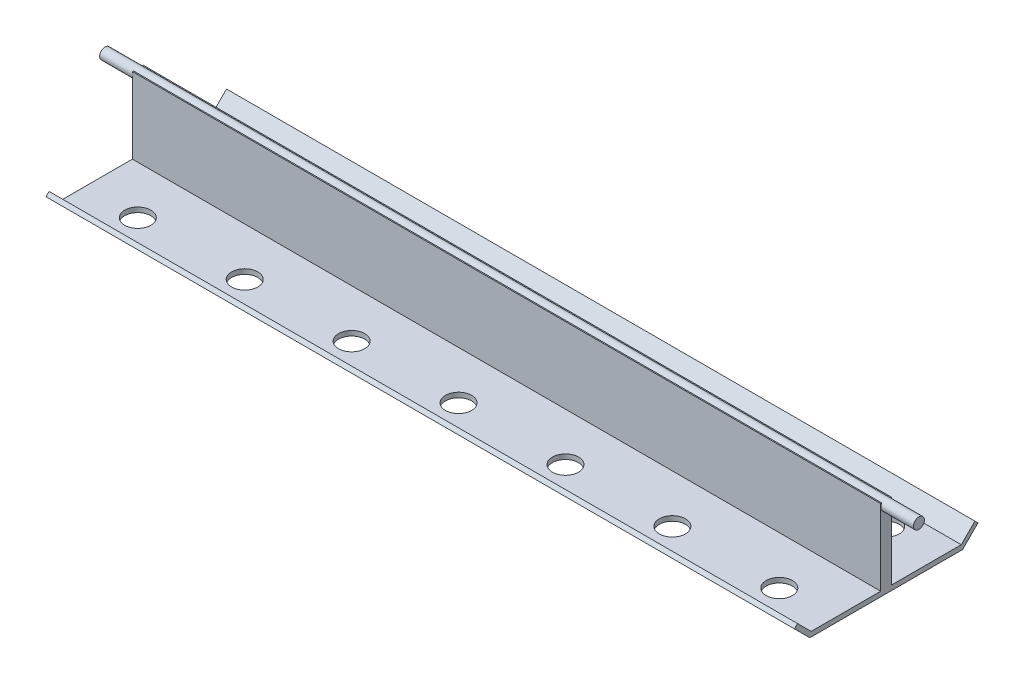
from build123d import *

# Parameters (mm, degrees)
SKETCH3_W                = 343
SKETCH3_H                = 5
BOSS_EXTRUDE1_DEPTH      = 35
SKETCH6_R                = 2.5
BOSS_EXTRUDE3_DEPTH      = 15
BOSS_EXTRUDE3_DEPTH_BACK = 358
BOSS_EXTRUDE4_DEPTH      = 343
SKETCH8_R                = 6
SKETCH8_R_2              = 5.999960458
CUT_EXTRUDE1_DEPTH       = 2.23071


with BuildPart() as part:
    # Sketch3 → Boss-Extrude1 (new body)
    with BuildSketch(Plane(origin=(0, 0, 0), x_dir=(1, 0, 0), z_dir=(0, 1, 0))):
        Rectangle(SKETCH3_W, SKETCH3_H)
    extrude(amount=BOSS_EXTRUDE1_DEPTH)

    # Sketch6 → Boss-Extrude3 (add, two sides)
    with BuildSketch(Plane.ZY.offset(171.5)) as boss_extrude3_sk:
        with Locations((0, 33.5)):
            Circle(SKETCH6_R)
    extrude(amount=BOSS_EXTRUDE3_DEPTH)
    extrude(boss_extrude3_sk.sketch, amount=-BOSS_EXTRUDE3_DEPTH_BACK)

    # Sketch7 → Boss-Extrude4 (add)
    with BuildSketch(Plane(origin=(171.5, 0, 0), x_dir=(0, 0, -1), z_dir=(1, 0, 0))):
        Polygon((35, -2), (42.071067812, 5.071067812), (40.656854249, 6.485281374), (34.402283019, 0.230710143), (-34.402283019, 0.230710143), (-40.656854249, 6.485281374), (-42.071067812, 5.071067812), (-35, -2), align=None)
    extrude(amount=-BOSS_EXTRUDE4_DEPTH)

    # Sketch8 → Cut-Extrude1 (cut)
    with BuildSketch(Plane(origin=(0, 0.230710143, 0), x_dir=(1, 0, 0), z_dir=(0, 1, 0))):
        with Locations((0, -24.5)):
            Circle(SKETCH8_R)
        with Locations((-49, -24.5)):
            Circle(SKETCH8_R_2)
        with Locations((-98, -24.5)):
            Circle(SKETCH8_R)
        with Locations((-147, -24.5)):
            Circle(SKETCH8_R)
        with Locations((147, -24.5)):
            Circle(SKETCH8_R)
        with Locations((98, -24.5)):
            Circle(SKETCH8_R)
        with Locations((49, -24.5)):
            Circle(SKETCH8_R_2)
        with Locations((98, 24.5)):
            Circle(SKETCH8_R)
        with Locations((147, 24.5)):
            Circle(SKETCH8_R)
        with Locations((49, 24.5)):
            Circle(SKETCH8_R_2)
        with Locations((0, 24.5)):
            Circle(SKETCH8_R)
        with Locations((-147, 24.5)):
            Circle(SKETCH8_R)
        with Locations((-98, 24.5)):
            Circle(SKETCH8_R)
        with Locations((-49, 24.5)):
            Circle(SKETCH8_R_2)
    extrude(amount=-CUT_EXTRUDE1_DEPTH, mode=Mode.SUBTRACT)


solid = part.part
